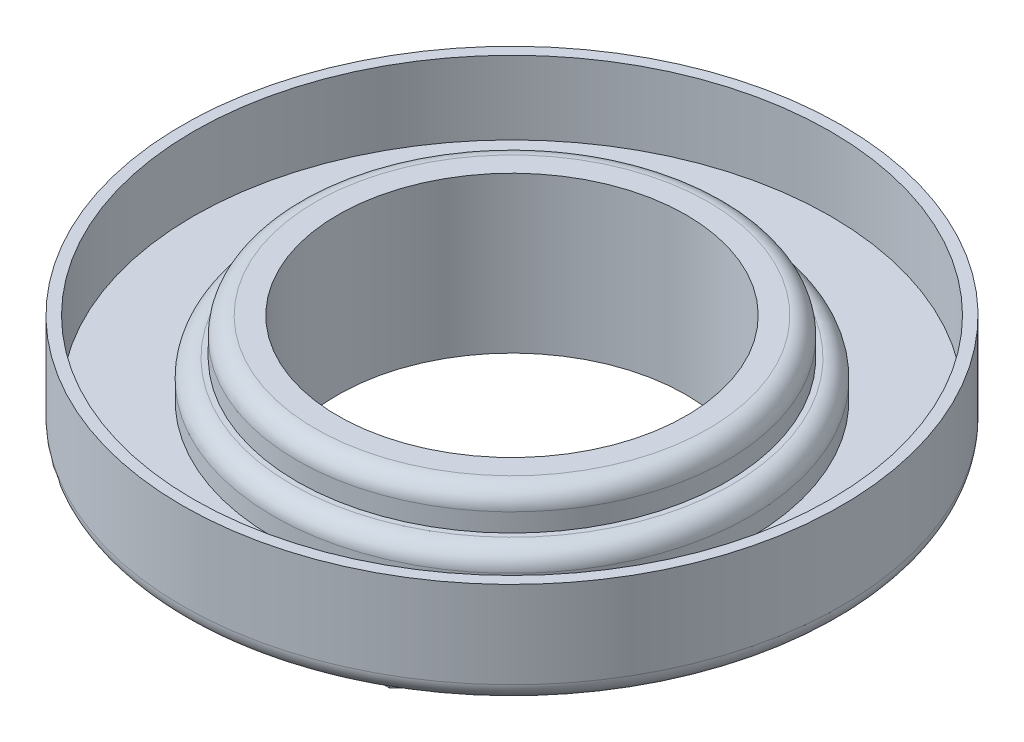
from build123d import *

# Parameters (mm, degrees)
BOSS_EXTRUDE1_DEPTH = 10.795
SKETCH2_R           = 22.8346
BOSS_EXTRUDE2_DEPTH = 7.2898
SKETCH3_R           = 22.0726
SKETCH3_R_2         = 16.51
CUT_EXTRUDE1_DEPTH  = 5.08
SKETCH4_R           = 12.065
CUT_EXTRUDE2_DEPTH  = 11.795
SKETCH5_R           = 18.1356
SKETCH5_R_2         = 14.8844
CUT_EXTRUDE5_DEPTH  = 2.54
FILLET1_R           = 1.27
FILLET2_R           = 1.27
FILLET3_R           = 1.27


with BuildPart() as part:
    # Sketch1 → Boss-Extrude1 (new body)
    with BuildSketch(Plane(origin=(0, 0, 0), x_dir=(1, 0, 0), z_dir=(0, 1, 0))):
        Polygon((-7.339781299, 15.8115), (7.339781299, 15.8115), (15.8115, 6.35), (15.8115, -6.35), (7.339781299, -15.8115), (-7.339781299, -15.8115), (-15.8115, -6.35), (-15.8115, 6.35), align=None)
    extrude(amount=BOSS_EXTRUDE1_DEPTH)

    # Sketch2 → Boss-Extrude2 (add)
    with BuildSketch(Plane(origin=(0, 3.5052, 0), x_dir=(-1, 0, 0), z_dir=(0, -1, 0))):
        Circle(SKETCH2_R)
    extrude(amount=-BOSS_EXTRUDE2_DEPTH)

    # Sketch3 → Cut-Extrude1 (cut)
    with BuildSketch(Plane(origin=(0, 10.795, 0), x_dir=(1, 0, 0), z_dir=(0, 1, 0))):
        Circle(SKETCH3_R)
        Circle(SKETCH3_R_2, mode=Mode.SUBTRACT)
    extrude(amount=-CUT_EXTRUDE1_DEPTH, mode=Mode.SUBTRACT)

    # Sketch4 → Cut-Extrude2 (cut, through all)
    with BuildSketch(Plane.XZ):
        Circle(SKETCH4_R)
    extrude(amount=-CUT_EXTRUDE2_DEPTH, mode=Mode.SUBTRACT)

    # Sketch5 → Cut-Extrude5 (cut)
    with BuildSketch(Plane(origin=(0, 10.795, 0), x_dir=(1, 0, 0), z_dir=(0, 1, 0))):
        Circle(SKETCH5_R)
        Circle(SKETCH5_R_2, mode=Mode.SUBTRACT)
    extrude(amount=-CUT_EXTRUDE5_DEPTH, mode=Mode.SUBTRACT)

    # Fillet1
    fillet1_edges = [part.edges().sort_by_distance(p)[0] for p in [
        (-14.8844, 10.795, 0),
    ]]
    fillet(fillet1_edges, radius=FILLET1_R)

    # Fillet2
    fillet2_edges = [part.edges().sort_by_distance(p)[0] for p in [
        (-16.51, 8.255, 0),
    ]]
    fillet(fillet2_edges, radius=FILLET2_R)

    # Fillet3
    fillet3_edges = [part.edges().sort_by_distance(p)[0] for p in [
        (22.8346, 3.5052, 0),
    ]]
    fillet(fillet3_edges, radius=FILLET3_R)


solid = part.part
